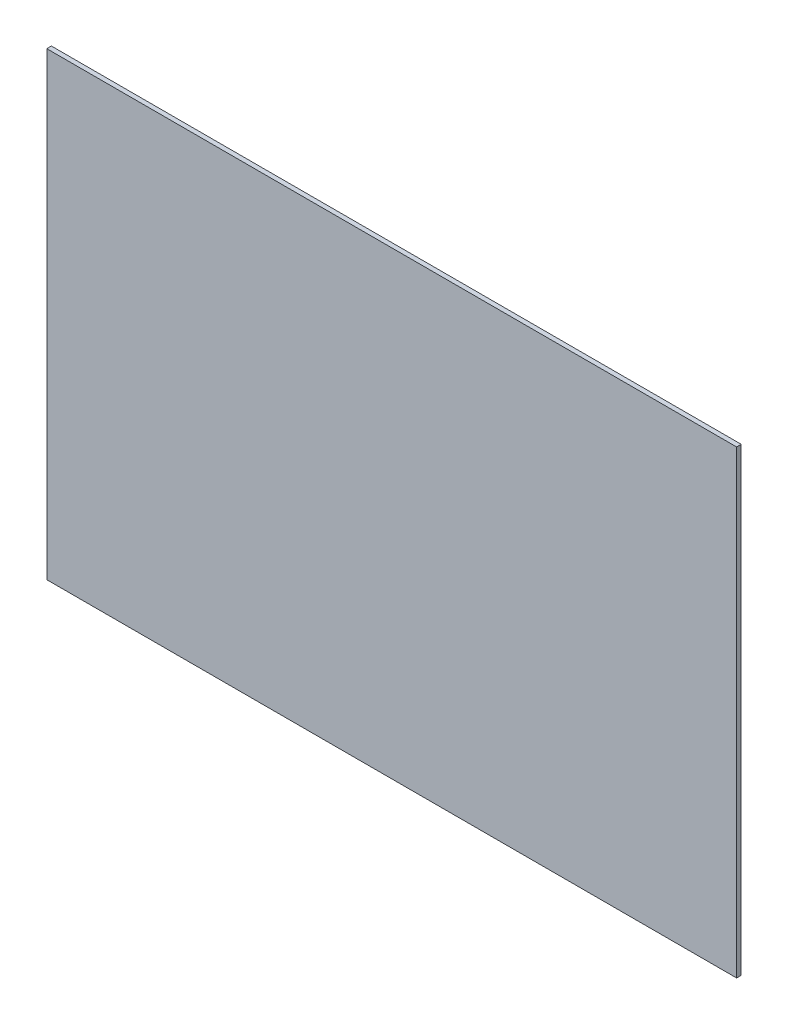
from build123d import *

# Parameters (mm, degrees)
SKETCH1_W           = 1500
SKETCH1_H           = 1000
BOSS_EXTRUDE1_DEPTH = 10


with BuildPart() as part:
    # Sketch1 → Boss-Extrude1 (new body)
    with BuildSketch(Plane.XY):
        Rectangle(SKETCH1_W, SKETCH1_H)
    extrude(amount=BOSS_EXTRUDE1_DEPTH)


solid = part.part
